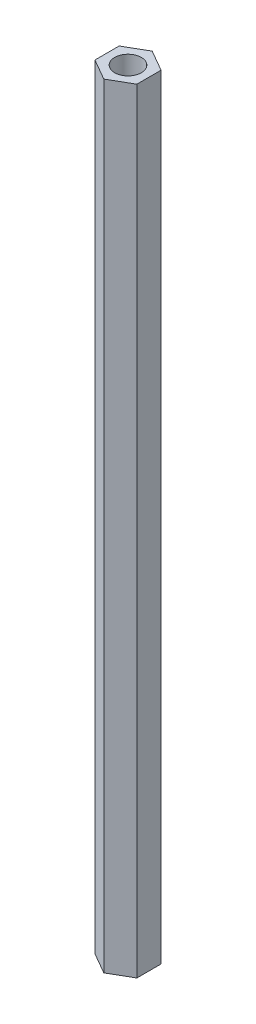
from build123d import *

# Parameters (mm, degrees)
SKETCH1_R           = 1.75
BOSS_EXTRUDE1_DEPTH = 101.6


with BuildPart() as part:
    # Sketch1 → Boss-Extrude1 (new body)
    with BuildSketch(Plane(origin=(0, 0, 0), x_dir=(1, 0, 0), z_dir=(0, 1, 0))):
        Polygon((2.75, -1.58771324), (2.75, 1.58771324), (0, 3.175426481), (-2.75, 1.58771324), (-2.75, -1.58771324), (0, -3.175426481), align=None)
        Circle(SKETCH1_R, mode=Mode.SUBTRACT)
    extrude(amount=BOSS_EXTRUDE1_DEPTH)


solid = part.part
